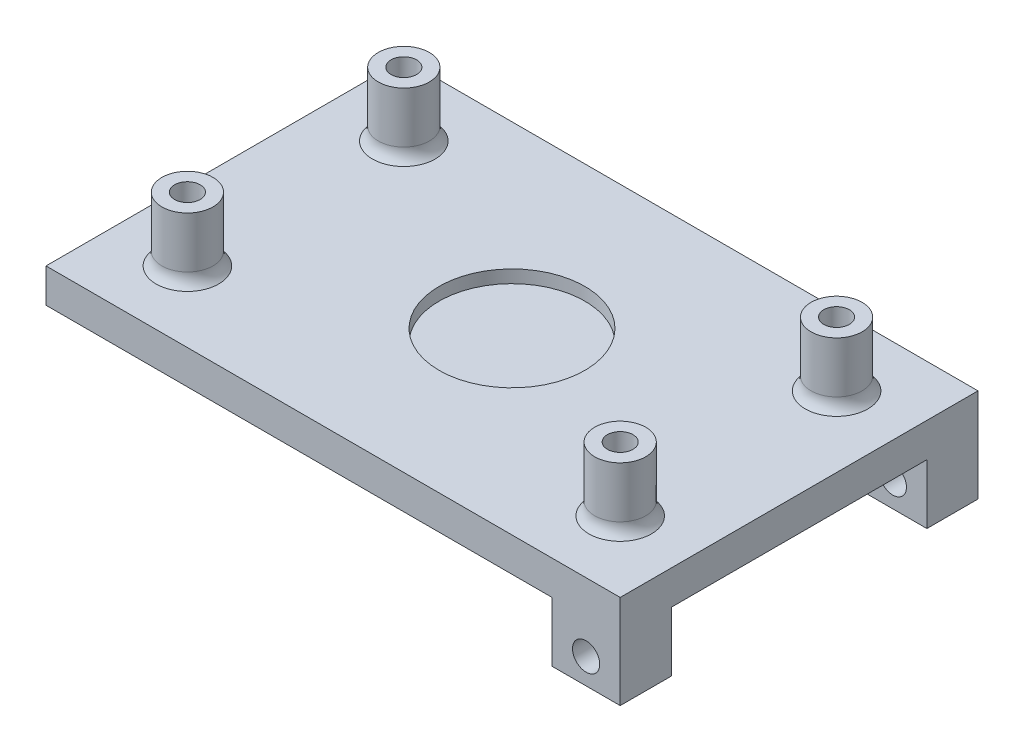
from build123d import *

# Parameters (mm, degrees)
SKETCH2_W                 = 75.4
SKETCH2_H                 = 50
BOSS_EXTRUDE1_DEPTH       = 3.5
SKETCH3_R                 = 1.5
CUT_EXTRUDE1_DEPTH        = 4
BOSS_EXTRUDE2_START       = 8
SKETCH4_R                 = 3
SKETCH4_R_2               = 1.5
BOSS_EXTRUDE2_DEPTH       = 8
MIRROR2_START             = 8
MIRROR2_COPY_1_SKETCH_R   = 3
MIRROR2_COPY_1_SKETCH_R_2 = 1.5
MIRROR2_COPY_1_DEPTH      = 8
FILLET1_R                 = 2
SKETCH6_W                 = 75.4
SKETCH6_H                 = 50
BOSS_EXTRUDE3_DEPTH       = 4
SKETCH9_R                 = 8.55
CUT_EXTRUDE2_DEPTH        = 1.5
SKETCH10_R                = 4.85
CUT_EXTRUDE3_DEPTH        = 1.87
SKETCH11_R                = 4
CUT_EXTRUDE4_DEPTH        = 0.5
CUT_EXTRUDE6_DEPTH        = 1.87
SKETCH14_W                = 8
SKETCH14_H                = 6
BOSS_EXTRUDE6_DEPTH       = 8
SKETCH15_R                = 1.6
CUT_EXTRUDE7_DEPTH        = 8
SKETCH16_W                = 4
SKETCH16_H                = 5
CUT_EXTRUDE8_DEPTH        = 8
SKETCH17_W                = 8
SKETCH17_H                = 6
CUT_EXTRUDE9_DEPTH        = 1


with BuildPart() as part:
    # Sketch2 → Boss-Extrude1 (new body)
    with BuildSketch(Plane(origin=(0, 0, 0), x_dir=(1, 0, 0), z_dir=(0, 1, 0))):
        with Locations((37.7, 25)):
            Rectangle(SKETCH2_W, SKETCH2_H)
    extrude(amount=BOSS_EXTRUDE1_DEPTH)

    # Sketch3 → Cut-Extrude1 (cut)
    with BuildSketch(Plane(origin=(0, 3.5, 0), x_dir=(1, 0, 0), z_dir=(0, 1, 0))):
        with Locations(Location((12.3, 37.7, 0), (0, 0, 270))):
            Circle(SKETCH3_R)
        with Locations(Location((12.3, 12.3, 0), (0, 0, 270))):
            Circle(SKETCH3_R)
        with Locations(Location((63.1, 37.7, 0), (0, 0, 270))):
            Circle(SKETCH3_R)
        with Locations(Location((63.1, 12.3, 0), (0, 0, 270))):
            Circle(SKETCH3_R)
    extrude(amount=-CUT_EXTRUDE1_DEPTH, mode=Mode.SUBTRACT)

    # Sketch4 → Boss-Extrude2 (add)
    with BuildSketch(Plane(origin=(0, 3.5, 0), x_dir=(1, 0, 0), z_dir=(0, 1, 0)).offset(BOSS_EXTRUDE2_START)):
        with Locations(Location((12.3, 37.7, 0), (0, 0, 90))):
            Circle(SKETCH4_R)
        with Locations(Location((12.3, 37.7, 0), (0, 0, 270))):
            Circle(SKETCH4_R_2, mode=Mode.SUBTRACT)
    boss_extrude2 = extrude(amount=-BOSS_EXTRUDE2_DEPTH)

    # Mirror1: Boss-Extrude2 across plane
    add(boss_extrude2.mirror(Plane.XY.offset(-25)))

    # Mirror2: Boss-Extrude2 across plane
    add(boss_extrude2.mirror(Plane.ZY.offset(-37.7)))

    # Mirror2 copy 1 sketch → Mirror2 copy 1 (add)
    with BuildSketch(Plane(origin=(75.4, 3.5, -50), x_dir=(-1, 0, 0), z_dir=(0, 1, 0)).offset(MIRROR2_START)):
        with Locations(Location((12.3, 37.7, 0), (0, 0, 90))):
            Circle(MIRROR2_COPY_1_SKETCH_R)
        with Locations(Location((12.3, 37.7, 0), (0, 0, 270))):
            Circle(MIRROR2_COPY_1_SKETCH_R_2, mode=Mode.SUBTRACT)
    extrude(amount=-MIRROR2_COPY_1_DEPTH)

    # Fillet1
    fillet1_edges = [part.edges().sort_by_distance(p)[0] for p in [
        (12.3, 3.5, -34.7),
        (12.3, 3.5, -15.3),
        (63.1, 3.5, -15.3),
        (63.1, 3.5, -34.7),
    ]]
    fillet(fillet1_edges, radius=FILLET1_R)

    # Sketch6 → Boss-Extrude3 (add)
    with BuildSketch(Plane.XZ):
        with Locations((37.7, -25)):
            Rectangle(SKETCH6_W, SKETCH6_H)
    extrude(amount=-BOSS_EXTRUDE3_DEPTH)

    # Sketch9 → Cut-Extrude2 (cut)
    with BuildSketch(Plane(origin=(0, 4, 0), x_dir=(1, 0, 0), z_dir=(0, 1, 0))):
        with Locations(Location((37.7, 25, 0), (0, 0, 270))):
            Circle(SKETCH9_R)
    extrude(amount=-CUT_EXTRUDE2_DEPTH, mode=Mode.SUBTRACT)

    # Sketch10 → Cut-Extrude3 (cut)
    with BuildSketch(Plane.XZ):
        with Locations(Location((17.699747997, -25, 0), (0, 0, 270))):
            Circle(SKETCH10_R)
    extrude(amount=-CUT_EXTRUDE3_DEPTH, mode=Mode.SUBTRACT)

    # Sketch11 → Cut-Extrude4 (cut)
    with BuildSketch(Plane.XZ.offset(-1.87)):
        with Locations(Location((17.699747997, -25, 0), (0, 0, 270))):
            Circle(SKETCH11_R)
    extrude(amount=-CUT_EXTRUDE4_DEPTH, mode=Mode.SUBTRACT)

    # Sketch12 → Cut-Extrude6 (cut)
    with BuildSketch(Plane.XZ):
        with BuildLine():
            Line((12.849747997, -25), (12.849747997, -27.5))
            Line((12.849747997, -27.5), (13.543728267, -27.5))
            ThreePointArc((13.543728267, -27.5), (13.026462445, -26.297267187), (12.849747997, -25))
        make_face()
        with BuildLine():
            Line((12.849747997, -22.5), (12.849747997, -25))
            ThreePointArc((12.849747997, -25), (13.026462445, -23.702732813), (13.543728267, -22.5))
            Line((13.543728267, -22.5), (12.849747997, -22.5))
        make_face()
        Polygon((0, -22.5), (0, -27.5), (12.849747997, -27.5), (12.849747997, -25), (12.849747997, -22.5), align=None)
    extrude(amount=-CUT_EXTRUDE6_DEPTH, mode=Mode.SUBTRACT)

    # Sketch14 → Boss-Extrude6 (add)
    with BuildSketch(Plane.XZ):
        with Locations((67.4, -7)):
            Rectangle(SKETCH14_W, SKETCH14_H)
    boss_extrude6 = extrude(amount=BOSS_EXTRUDE6_DEPTH)

    # Sketch15 → Cut-Extrude7 (cut)
    with BuildSketch(Plane(origin=(0, 0, -10), x_dir=(-1, 0, 0), z_dir=(0, 0, -1))):
        with Locations((-67.4, -4)):
            Circle(SKETCH15_R)
    cut_extrude7 = extrude(amount=-CUT_EXTRUDE7_DEPTH, mode=Mode.SUBTRACT)

    # Mirror4: Boss-Extrude6, Cut-Extrude7 across plane
    add(boss_extrude6.mirror(Plane.XY.offset(-25)))
    add(cut_extrude7.mirror(Plane.XY.offset(-25)), mode=Mode.SUBTRACT)

    # Sketch16 → Cut-Extrude8 (cut)
    with BuildSketch(Plane.XZ):
        Polygon((4, -46), (4, -27.5), (0, -27.5), (0, -50), (4, -50), align=None)
        with Locations((2, -25)):
            Rectangle(SKETCH16_W, SKETCH16_H)
        Polygon((4, -22.5), (4, -4), (4, 0), (0, 0), (0, -22.5), align=None)
        Polygon((63.4, -4), (71.4, -4), (71.4, -10), (71.4, -40), (71.4, -46), (63.4, -46), (4, -46), (4, -50), (75.4, -50), (75.4, 0), (4, 0), (4, -4), align=None)
    extrude(amount=-CUT_EXTRUDE8_DEPTH, mode=Mode.SUBTRACT)

    # Sketch17 → Cut-Extrude9 (cut)
    with BuildSketch(Plane.XZ.offset(8)):
        with Locations((67.4, -43)):
            Rectangle(SKETCH17_W, SKETCH17_H)
        with Locations((67.4, -7)):
            Rectangle(SKETCH17_W, SKETCH17_H)
    extrude(amount=-CUT_EXTRUDE9_DEPTH, mode=Mode.SUBTRACT)


solid = part.part
